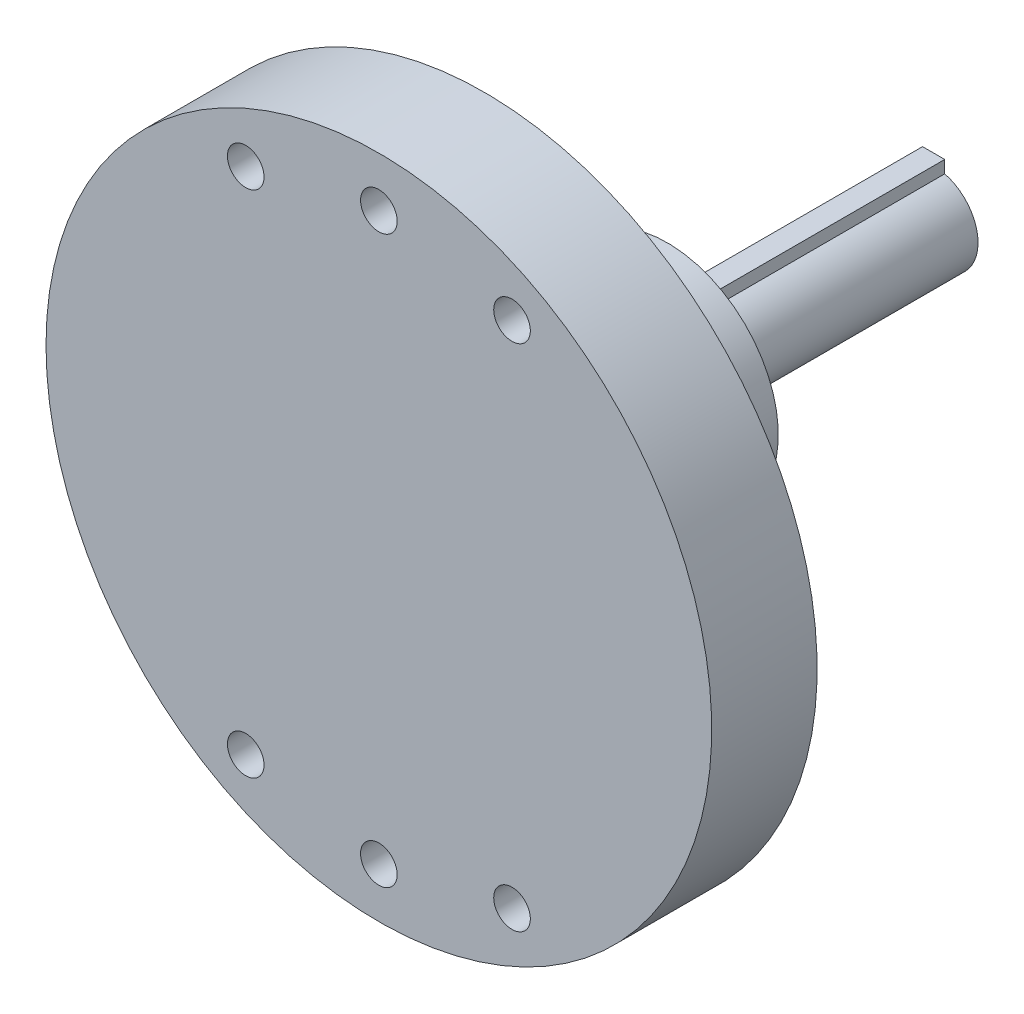
from build123d import *

# Parameters (mm, degrees)
SKETCH1_W                  = 30
SKETCH1_H                  = 9.5
CUT_EXTRUDE1_DEPTH         = 3.5
SKETCH3_R                  = 17.4
BOSS_EXTRUDE1_DEPTH        = 4
SKETCH4_R                  = 10
BOSS_EXTRUDE2_DEPTH        = 16
CUT_EXTRUDE2_DEPTH         = 50.759421218
SKETCH6_W                  = 4
SKETCH6_H                  = 26
F_4_CLEARANCE_HOLE1_D      = 3.3
F_2_CLEARANCE_HOLE1_D      = 2.5
F_2_CLEARANCE_HOLE1_DEPTH  = 12
F_2_CLEARANCE_HOLE2_REACH  = 54.582
F_2_CLEARANCE_HOLE2_BORE_R = 1.25
F_2_CLEARANCE_HOLE3_D      = 2.5
F_2_CLEARANCE_HOLE3_DEPTH  = 40
FILLET1_R                  = 3
EXTRUDE_1_DEPTH            = 50


with BuildPart() as part:
    # Sketch1 → Revolve1 (revolve)
    with BuildSketch(Plane.XZ, mode=Mode.PRIVATE) as revolve1_sk:
        with Locations((15, 5.25)):
            Rectangle(SKETCH1_W, SKETCH1_H)
    revolve(revolve1_sk.sketch.rotate(Axis((0, 0, 10), (0, 0, -1)), 180), axis=Axis((0, 0, 10), (0, 0, -1)))

    # Sketch2 → Cut-Extrude1 (cut)
    with BuildSketch(Plane(origin=(0, 0, 0.5), x_dir=(-1, 0, 0), z_dir=(0, 0, -1))):
        with BuildLine():
            ThreePointArc((1.901854596, -26.932934283), (6.318658968, -26.250229501), (10.562335147, -24.848281153))
            ThreePointArc((10.562335147, -24.848281153), (13.103370267, -25.060195635), (14.379253383, -22.852506912))
            ThreePointArc((14.379253383, -22.852506912), (27, 0), (14.379253383, 22.852506912))
            ThreePointArc((14.379253383, 22.852506912), (13.103370267, 25.060195635), (10.562335147, 24.848281153))
            ThreePointArc((10.562335147, 24.848281153), (6.318658968, 26.250229501), (1.901854596, 26.932934283))
            ThreePointArc((1.901854596, 26.932934283), (0, 27.88125), (-1.901854596, 26.932934283))
            ThreePointArc((-1.901854596, 26.932934283), (-6.318658968, 26.250229501), (-10.562335147, 24.848281153))
            ThreePointArc((-10.562335147, 24.848281153), (-13.103370267, 25.060195635), (-14.379253383, 22.852506912))
            ThreePointArc((-14.379253383, 22.852506912), (-27, 0), (-14.379253383, -22.852506912))
            ThreePointArc((-14.379253383, -22.852506912), (-13.103370267, -25.060195635), (-10.562335147, -24.848281153))
            ThreePointArc((-10.562335147, -24.848281153), (-6.318658968, -26.250229501), (-1.901854596, -26.932934283))
            ThreePointArc((-1.901854596, -26.932934283), (0, -27.88125), (1.901854596, -26.932934283))
        make_face()
    extrude(amount=-CUT_EXTRUDE1_DEPTH, mode=Mode.SUBTRACT)

    # Sketch3 → Boss-Extrude1 (add)
    with BuildSketch(Plane(origin=(0, 0, 4), x_dir=(-1, 0, 0), z_dir=(0, 0, -1))):
        Circle(SKETCH3_R)
    extrude(amount=BOSS_EXTRUDE1_DEPTH)

    # Sketch4 → Boss-Extrude2 (add)
    with BuildSketch(Plane(origin=(0, 0, 0), x_dir=(-1, 0, 0), z_dir=(0, 0, -1))):
        Circle(SKETCH4_R)
    extrude(amount=BOSS_EXTRUDE2_DEPTH)

    # Sketch5 → Cut-Extrude2 (cut, through all)
    with BuildSketch(Plane.XY.offset(10)):
        with BuildLine():
            Line((1, 5), (-1, 5))
            Line((-1, 5), (-1, 3.872983346))
            ThreePointArc((-1, 3.872983346), (0, 4), (1, 3.872983346))
            Line((1, 3.872983346), (1, 5))
        make_face()
    extrude(amount=-CUT_EXTRUDE2_DEPTH, mode=Mode.SUBTRACT)

    # Sketch6 → Cut-Revolve1 (revolve, cut)
    with BuildSketch(Plane.XZ):
        with Locations((2, -3)):
            Rectangle(SKETCH6_W, SKETCH6_H)
    revolve(axis=Axis((0, 0, 10), (0, 0, -1)), mode=Mode.SUBTRACT)

    # #4 Clearance Hole1 (through all)
    with Locations(Plane(origin=(0, 0, 4), x_dir=(-1, 0, 0), z_dir=(0, 0, -1))):
        with Locations((12, -22.95), (0, -25.5), (-12, -22.95), (-12, 22.95), (0, 25.5), (12, 22.95)):
            Hole(F_4_CLEARANCE_HOLE1_D / 2)

    # #2 Clearance Hole1
    with Locations(Plane(origin=(0, 0, -16), x_dir=(-1, 0, 0), z_dir=(0, 0, -1))):
        with Locations((-5.055813485, -5.055813485), (5.055813485, -5.055813485), (5.055813485, 5.055813485), (-5.055813485, 5.055813485)):
            Hole(F_2_CLEARANCE_HOLE1_D / 2, depth=F_2_CLEARANCE_HOLE1_DEPTH)

    # #2 Clearance Hole2 bore (on position points) → #2 Clearance Hole2 (cut, up to next)
    with BuildSketch(Plane(origin=(0, -10, -6.276306458), x_dir=(-1, 0, 0), z_dir=(0, -1, 0)), mode=Mode.PRIVATE) as f_2_clearance_hole2_sk1:
        Circle(F_2_CLEARANCE_HOLE2_BORE_R)
    f_2_clearance_hole2_tool1 = extrude(f_2_clearance_hole2_sk1.sketch, amount=-F_2_CLEARANCE_HOLE2_REACH, mode=Mode.PRIVATE) & part.part
    add(f_2_clearance_hole2_tool1.solids().sort_by_distance((0, -10, -6.276306))[0], mode=Mode.SUBTRACT)

    # #2 Clearance Hole3
    with Locations(Plane(origin=(0, 10, -6.276306458), x_dir=(1, 0, 0), z_dir=(0, 1, 0))):
        with Locations((0, 0)):
            Hole(F_2_CLEARANCE_HOLE3_D / 2, depth=F_2_CLEARANCE_HOLE3_DEPTH)

    # Fillet1
    fillet1_edges = [part.edges().sort_by_distance(p)[0] for p in [
        (10, 0, 0),
    ]]
    fillet(fillet1_edges, radius=FILLET1_R)

    # 草图1 → 凸台-拉伸1 (add)
    with BuildSketch(Plane.XY.offset(10)):
        with BuildLine():
            Line((-1, 5), (-1, 3.872983346))
            ThreePointArc((-1, 3.872983346), (0, -4), (1, 3.872983346))
            Line((1, 3.872983346), (1, 5))
            Line((1, 5), (-1, 5))
        make_face()
    extrude(amount=-EXTRUDE_1_DEPTH)


solid = part.part
